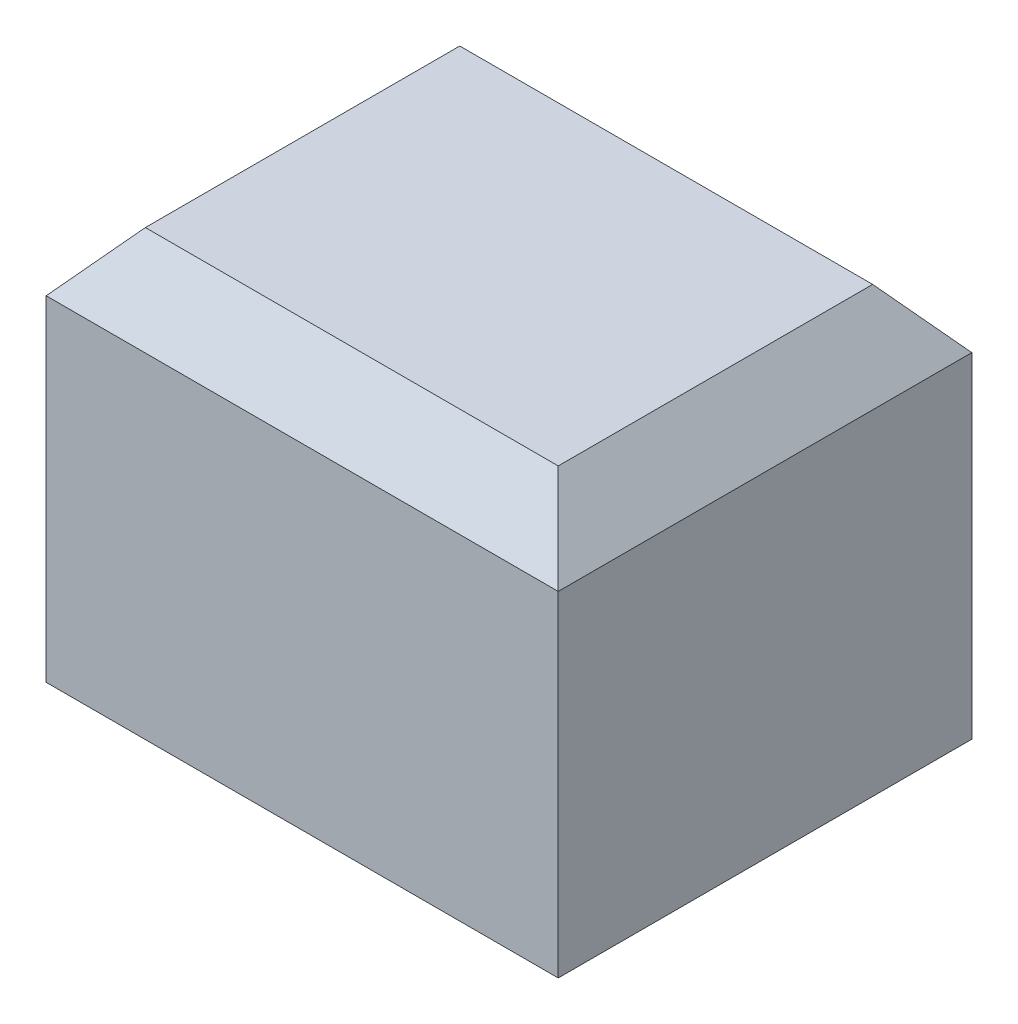
from build123d import *

# Parameters (mm, degrees)
SKETCH1_W                = 5.2
SKETCH1_H                = 4.2
SKETCH1_W_2              = 3
SKETCH1_H_2              = 2
BODY_EXTRUDE_DEPTH       = 2.8
SKETCH2_W                = 5.2
SKETCH2_H                = 4.2
CAP_EXTRUDE_DEPTH        = 1.2
BED_CHAMFER_SIZE         = 0.6
BED_CHAMFER_SIZE2        = 0.503459779
BED_CHAMFER_PART_2_SIZE  = 0.6
BED_CHAMFER_PART_2_SIZE2 = 0.503459779
BED_CHAMFER_PART_3_SIZE  = 0.6
BED_CHAMFER_PART_3_SIZE2 = 0.503459779
BED_CHAMFER_PART_4_SIZE  = 0.6
BED_CHAMFER_PART_4_SIZE2 = 0.503459779


with BuildPart() as part:
    # Sketch1 → Body Extrude (new body)
    with BuildSketch(Plane(origin=(0, 0, 0), x_dir=(1, 0, 0), z_dir=(0, 1, 0))):
        Rectangle(SKETCH1_W, SKETCH1_H)
        Rectangle(SKETCH1_W_2, SKETCH1_H_2, mode=Mode.SUBTRACT)
    extrude(amount=BODY_EXTRUDE_DEPTH)

    # Sketch2 → Cap Extrude (add)
    with BuildSketch(Plane(origin=(0, 2.8, 0), x_dir=(1, 0, 0), z_dir=(0, 1, 0))):
        Rectangle(SKETCH2_W, SKETCH2_H)
    extrude(amount=CAP_EXTRUDE_DEPTH)

    # Bed Chamfer
    bed_chamfer_edges = [part.edges().sort_by_distance(p)[0] for p in [
        (-2.6, 4, 0),
    ]]
    bed_chamfer_side = [part.faces().sort_by_distance(p)[0] for p in [
        (-2.6, 2, 0),
    ]]
    chamfer(bed_chamfer_edges, length=BED_CHAMFER_SIZE, length2=BED_CHAMFER_SIZE2, reference=bed_chamfer_side[0])

    # Bed Chamfer part 2
    bed_chamfer_part_2_edges = [part.edges().sort_by_distance(p)[0] for p in [
        (0, 4, 2.1),
    ]]
    bed_chamfer_part_2_side = [part.faces().sort_by_distance(p)[0] for p in [
        (0, 2, 2.1),
    ]]
    chamfer(bed_chamfer_part_2_edges, length=BED_CHAMFER_PART_2_SIZE, length2=BED_CHAMFER_PART_2_SIZE2, reference=bed_chamfer_part_2_side[0])

    # Bed Chamfer part 3
    bed_chamfer_part_3_edges = [part.edges().sort_by_distance(p)[0] for p in [
        (2.6, 4, 0),
    ]]
    bed_chamfer_part_3_side = [part.faces().sort_by_distance(p)[0] for p in [
        (2.6, 2, 0),
    ]]
    chamfer(bed_chamfer_part_3_edges, length=BED_CHAMFER_PART_3_SIZE, length2=BED_CHAMFER_PART_3_SIZE2, reference=bed_chamfer_part_3_side[0])

    # Bed Chamfer part 4
    bed_chamfer_part_4_edges = [part.edges().sort_by_distance(p)[0] for p in [
        (0, 4, -2.1),
    ]]
    bed_chamfer_part_4_side = [part.faces().sort_by_distance(p)[0] for p in [
        (0, 2, -2.1),
    ]]
    chamfer(bed_chamfer_part_4_edges, length=BED_CHAMFER_PART_4_SIZE, length2=BED_CHAMFER_PART_4_SIZE2, reference=bed_chamfer_part_4_side[0])


solid = part.part
